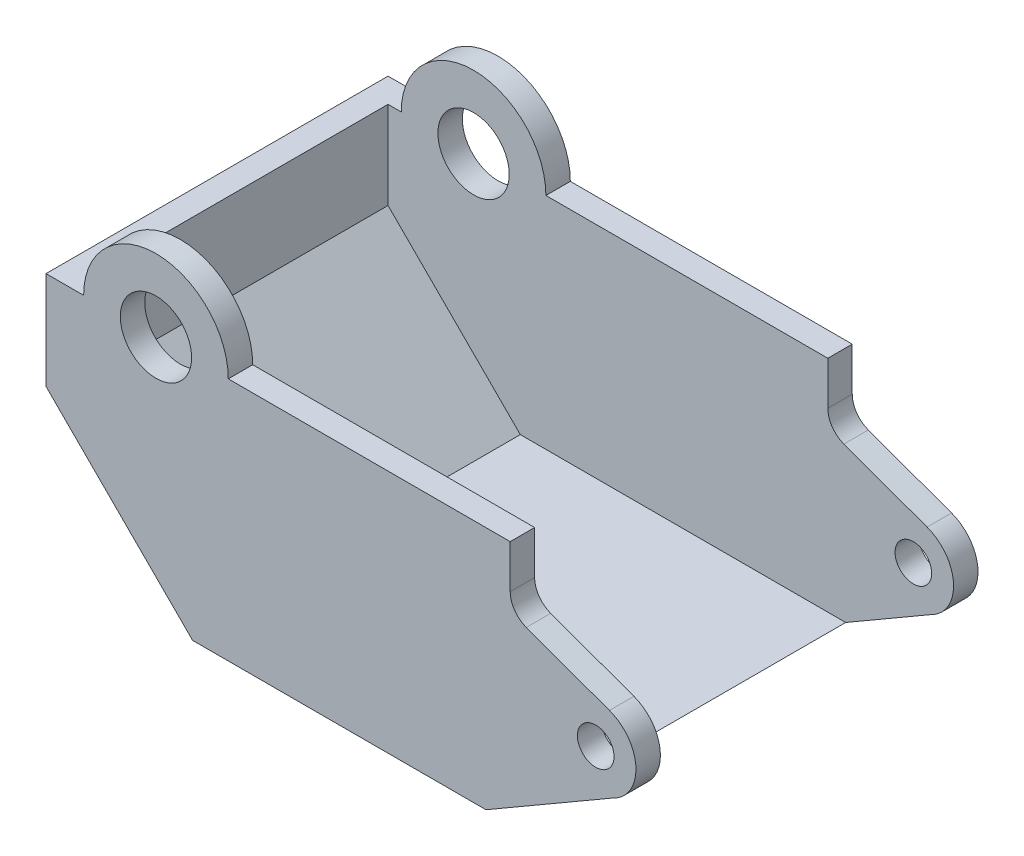
from build123d import *

# Parameters (mm, degrees)
BOSS_EXTRUDE2_DEPTH = 22.58314
SHELL3_T            = -1.6129
SKETCH2_R           = 2.35458
SKETCH2_R_2         = 1.20904
CUT_EXTRUDE1_DEPTH  = 23.58314


with BuildPart() as part:
    # Sketch1 → Boss-Extrude2 (new body)
    with BuildSketch(Plane.XY):
        with BuildLine():
            Line((-17.869818431, 7.881581433), (-20.353938431, 7.881581433))
            Line((-20.353938431, 7.881581433), (-20.353938431, 1.429981433))
            Line((-20.353938431, 1.429981433), (-10.676538431, -8.249958567))
            Line((-10.676538431, -8.249958567), (8.693302541, -8.249958567))
            Line((8.693302541, -8.249958567), (17.046970588, -3.405940625))
            ThreePointArc((17.046970588, -3.405940625), (18.594805131, -0.883615337), (16.848949341, 1.505925245))
            Line((16.848949341, 1.505925245), (11.35487534, 3.505941031))
            ThreePointArc((11.35487534, 3.505941031), (10.585366229, 4.096455714), (10.293701569, 5.021541433))
            Line((10.293701569, 5.021541433), (10.293701569, 7.881581433))
            Line((10.293701569, 7.881581433), (-8.319418431, 7.881581433))
            ThreePointArc((-8.319418431, 7.881581433), (-13.094618431, 12.656781433), (-17.869818431, 7.881581433))
        make_face()
    extrude(amount=BOSS_EXTRUDE2_DEPTH)

    # Shell3
    shell3_openings = [part.faces().sort_by_distance(p)[0] for p in [
        (0.987141569, 7.881581433, 11.29157),
        (10.293701569, 6.451561433, 11.29157),
        (10.704827342, 4.180098473, 11.29157),
        (14.10191234, 2.505933138, 11.29157),
        (17.771382548, -0.916811514, 11.29157),
        (12.870136565, -5.827949596, 11.29157),
        (-19.111878431, 7.881581433, 11.29157),
        (-13.094618431, 10.269181433, 11.29157),
    ]]
    offset(amount=SHELL3_T, openings=shell3_openings, kind=Kind.INTERSECTION)

    # Sketch2 → Cut-Extrude1 (cut, through all)
    with BuildSketch(Plane.XY.offset(22.58314)):
        with Locations((-13.094618431, 7.881581433)):
            Circle(SKETCH2_R)
        with Locations((15.940121569, -0.990638567)):
            Circle(SKETCH2_R_2)
    extrude(amount=-CUT_EXTRUDE1_DEPTH, mode=Mode.SUBTRACT)


solid = part.part
